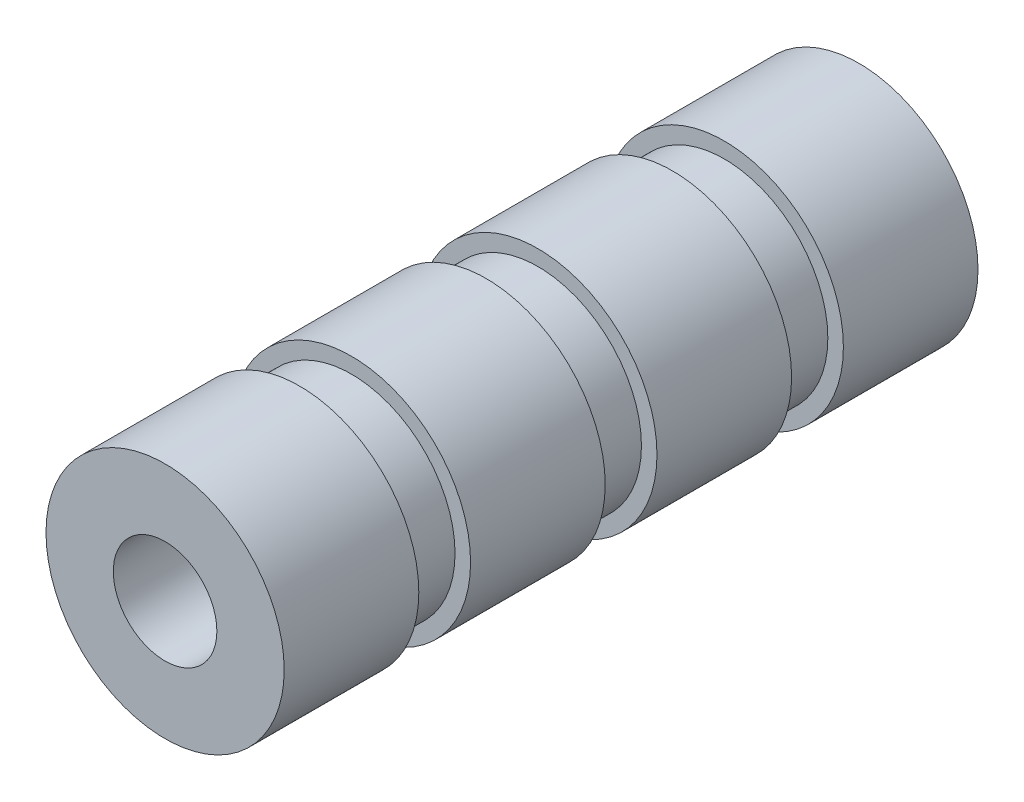
from build123d import *

# Parameters (mm, degrees)
SKETCH1_R           = 11.5
BOSS_EXTRUDE1_DEPTH = 13
SKETCH2_R           = 10
BOSS_EXTRUDE2_DEPTH = 5
SKETCH3_R           = 11.5
BOSS_EXTRUDE3_DEPTH = 13
SKETCH4_R           = 10
BOSS_EXTRUDE4_DEPTH = 5
SKETCH5_R           = 11.5
BOSS_EXTRUDE5_DEPTH = 13
SKETCH6_R           = 10
BOSS_EXTRUDE6_DEPTH = 5
SKETCH7_R           = 11.5
BOSS_EXTRUDE7_DEPTH = 13
SKETCH8_R           = 5
CUT_EXTRUDE1_DEPTH  = 68


with BuildPart() as part:
    # Sketch1 → Boss-Extrude1 (new body)
    with BuildSketch(Plane.XY):
        Circle(SKETCH1_R)
    extrude(amount=BOSS_EXTRUDE1_DEPTH)

    # Sketch2 → Boss-Extrude2 (add)
    with BuildSketch(Plane.XY.offset(13)):
        Circle(SKETCH2_R)
    extrude(amount=BOSS_EXTRUDE2_DEPTH)

    # Sketch3 → Boss-Extrude3 (add)
    with BuildSketch(Plane.XY.offset(18)):
        Circle(SKETCH3_R)
    extrude(amount=BOSS_EXTRUDE3_DEPTH)

    # Sketch4 → Boss-Extrude4 (add)
    with BuildSketch(Plane.XY.offset(31)):
        Circle(SKETCH4_R)
    extrude(amount=BOSS_EXTRUDE4_DEPTH)

    # Sketch5 → Boss-Extrude5 (add)
    with BuildSketch(Plane.XY.offset(36)):
        Circle(SKETCH5_R)
    extrude(amount=BOSS_EXTRUDE5_DEPTH)

    # Sketch6 → Boss-Extrude6 (add)
    with BuildSketch(Plane.XY.offset(49)):
        Circle(SKETCH6_R)
    extrude(amount=BOSS_EXTRUDE6_DEPTH)

    # Sketch7 → Boss-Extrude7 (add)
    with BuildSketch(Plane.XY.offset(54)):
        Circle(SKETCH7_R)
    extrude(amount=BOSS_EXTRUDE7_DEPTH)

    # Sketch8 → Cut-Extrude1 (cut, through all)
    with BuildSketch(Plane.XY.offset(67)):
        Circle(SKETCH8_R)
    extrude(amount=-CUT_EXTRUDE1_DEPTH, mode=Mode.SUBTRACT)


solid = part.part
